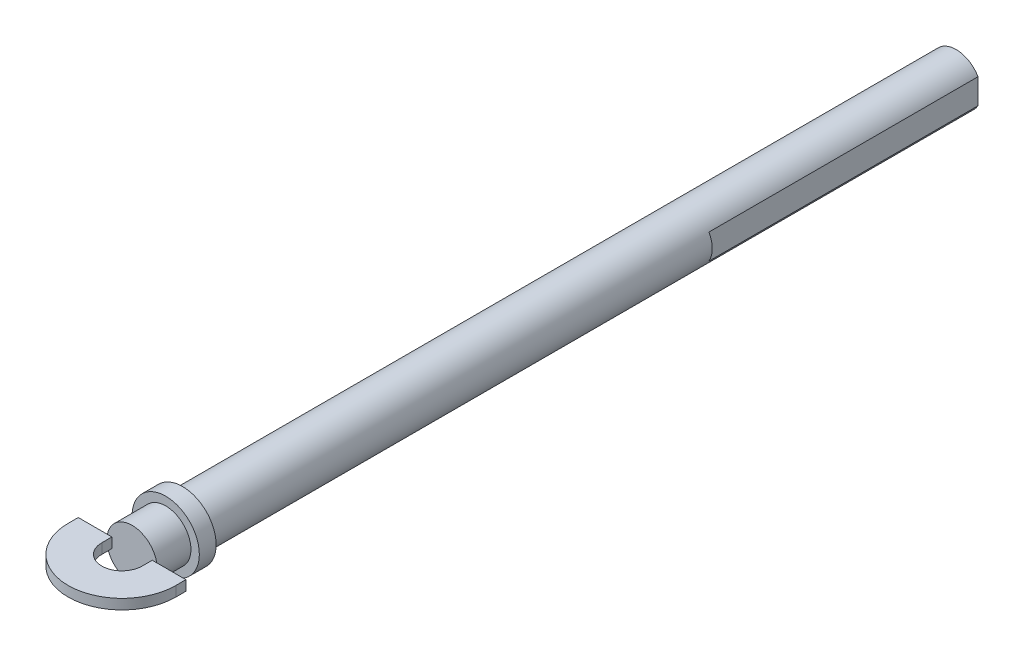
from build123d import *

# Parameters (mm, degrees)
SKETCH1_R           = 7.5
BOSS_EXTRUDE1_DEPTH = 230
SKETCH2_R           = 10
BOSS_EXTRUDE2_DEPTH = 5
SKETCH3_R           = 7.5
BOSS_EXTRUDE3_DEPTH = 10
CUT_EXTRUDE1_DEPTH  = 80
EXTRUDE_THIN1_DEPTH = 1.5


with BuildPart() as part:
    # Sketch1 → Boss-Extrude1 (new body)
    with BuildSketch(Plane.XY):
        Circle(SKETCH1_R)
    extrude(amount=BOSS_EXTRUDE1_DEPTH)

    # Sketch2 → Boss-Extrude2 (add)
    with BuildSketch(Plane.XY.offset(230)):
        Circle(SKETCH2_R)
    extrude(amount=BOSS_EXTRUDE2_DEPTH)

    # Sketch3 → Boss-Extrude3 (add)
    with BuildSketch(Plane.XY.offset(235)):
        Circle(SKETCH3_R)
    extrude(amount=BOSS_EXTRUDE3_DEPTH)

    # Sketch4 → Cut-Extrude1 (cut)
    with BuildSketch(Plane(origin=(0, 0, 0), x_dir=(-1, 0, 0), z_dir=(0, 0, -1))):
        with BuildLine():
            Line((-6.5, 3.741657387), (-6.5, -3.741657387))
            ThreePointArc((-6.5, -3.741657387), (-7.5, 0), (-6.5, 3.741657387))
        make_face()
        with BuildLine():
            Line((6.5, 3.741657387), (6.5, -3.741657387))
            ThreePointArc((6.5, -3.741657387), (7.5, 0), (6.5, 3.741657387))
        make_face()
    extrude(amount=-CUT_EXTRUDE1_DEPTH, mode=Mode.SUBTRACT)

    # Sketch5 → Extrude-Thin1 (add, symmetric)
    with BuildSketch(Plane(origin=(0, 0, 0), x_dir=(1, 0, 0), z_dir=(0, 1, 0))):
        with BuildLine():
            Line((-6, -245), (-6, -248))
            ThreePointArc((-6, -248), (0, -254), (6, -248))
            Line((6, -248), (6, -245))
            Line((6, -245), (16, -245))
            Line((16, -245), (16, -248))
            ThreePointArc((16, -248), (0, -264), (-16, -248))
            Line((-16, -248), (-16, -245))
            Line((-16, -245), (-6, -245))
        make_face()
    extrude(amount=EXTRUDE_THIN1_DEPTH, both=True)


solid = part.part
